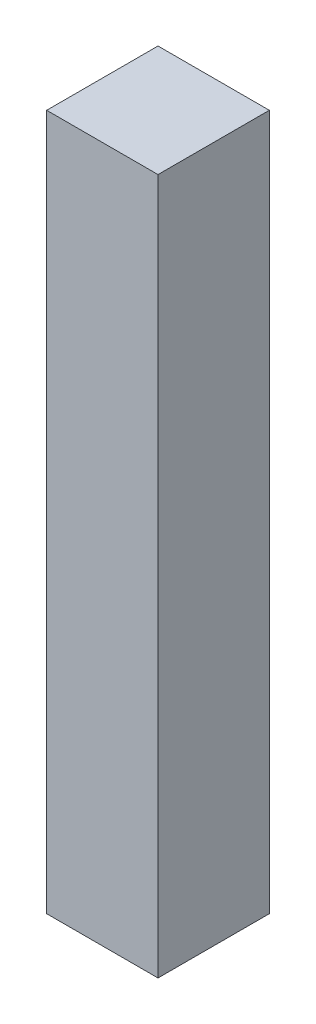
from build123d import *

# Parameters (mm, degrees)
SKETCH1_W           = 40
SKETCH1_H           = 250
BOSS_EXTRUDE1_DEPTH = 40


with BuildPart() as part:
    # Sketch1 → Boss-Extrude1 (new body)
    with BuildSketch(Plane.XY):
        Rectangle(SKETCH1_W, SKETCH1_H)
    extrude(amount=BOSS_EXTRUDE1_DEPTH)


solid = part.part
